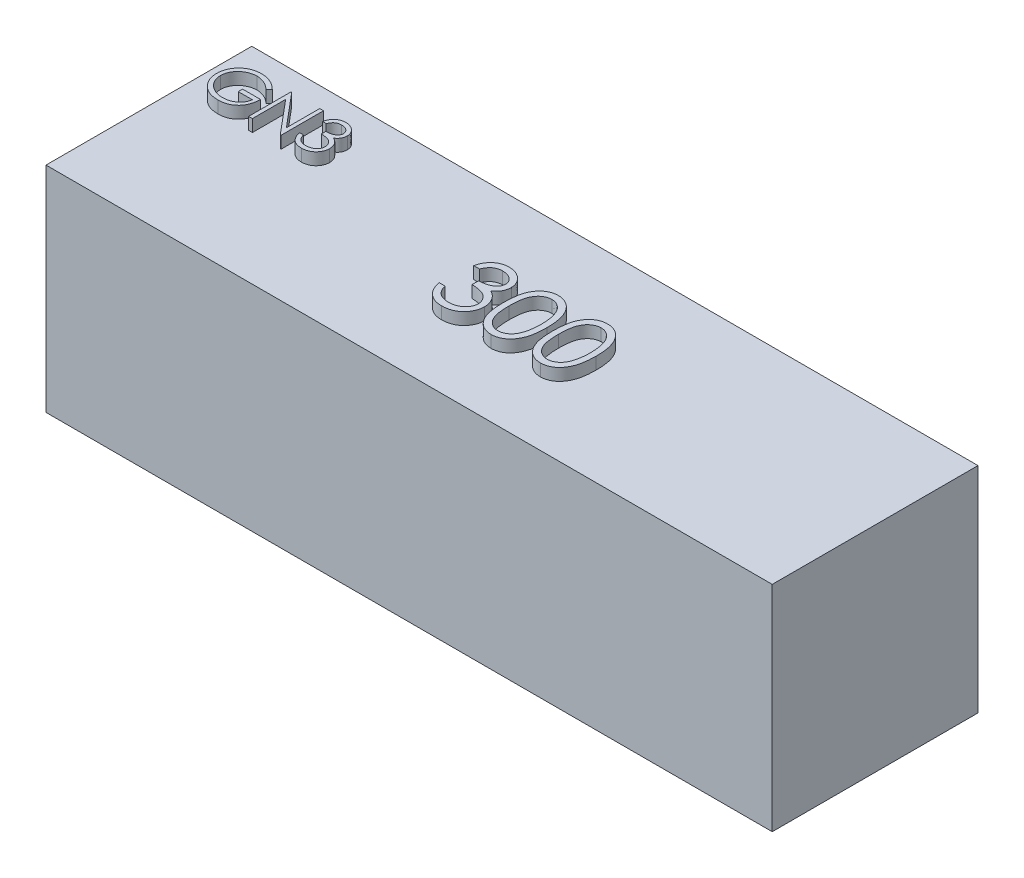
from build123d import *

# Parameters (mm, degrees)
SKETCH5_W           = 60
SKETCH5_H           = 17.7
BOSS_EXTRUDE2_DEPTH = 17
BOSS_EXTRUDE3_DEPTH = 1


with BuildPart() as part:
    # Sketch5 → Boss-Extrude2 (new body)
    with BuildSketch(Plane.XY):
        with Locations((30, 8.85)):
            Rectangle(SKETCH5_W, SKETCH5_H)
    extrude(amount=BOSS_EXTRUDE2_DEPTH)

    # Sketch6 → Boss-Extrude3 (add)
    with BuildSketch(Plane(origin=(0, 17.7, 0), x_dir=(1, 0, 0), z_dir=(0, 1, 0))):
        with BuildLine():
            Line((4.942496515, -3.246050022), (4.673265746, -3.501258356))
            add(Edge.make_bspline(
                [(4.673265746, -3.501258356), (4.624546858, -3.455427493), (4.528270811, -3.36485863), (4.371310569, -3.247347635), (4.207546935, -3.146681534), (4.037834438, -3.064775298), (3.866375884, -2.999422537), (3.695447107, -2.952894397), (3.526801406, -2.92322186), (3.414634188, -2.91967349), (3.359363502, -2.917925022)],
                knots=[0, 0, 0, 0, 0.000200536, 0.000396289, 0.000586999, 0.000776397, 0.000960787, 0.001136655, 0.001307246, 0.001472961, 0.001472961, 0.001472961, 0.001472961], degree=3))
            add(Edge.make_bspline(
                [(3.359363502, -2.917925022), (3.325448802, -2.918338628), (3.257707362, -2.919164767), (3.157085418, -2.929708983), (3.057518781, -2.944873847), (2.959195406, -2.966815724), (2.86192412, -2.994624784), (2.766043227, -3.029410247), (2.671373873, -3.069965491), (2.578807792, -3.116827965), (2.489067288, -3.168307811), (2.404310452, -3.225356352), (2.323997053, -3.286145142), (2.249636628, -3.352196121), (2.180801441, -3.422910987), (2.11585307, -3.496974293), (2.057075774, -3.576409511), (2.003984609, -3.659755137), (1.95662299, -3.745547327), (1.914814337, -3.832960316), (1.879717249, -3.921704171), (1.851947793, -4.011890248), (1.829037139, -4.102820838), (1.812919532, -4.195125559), (1.80383281, -4.288903244), (1.80226103, -4.351700503), (1.801470874, -4.383269574)],
                knots=[0, 0, 0, 0, 0.000101701, 0.000203139, 0.000303193, 0.000403728, 0.000505139, 0.000606491, 0.000709509, 0.000813922, 0.000917583, 0.001019673, 0.001120217, 0.001219549, 0.001317716, 0.001416124, 0.001514842, 0.00161384, 0.001712379, 0.001808658, 0.001904353, 0.001998376, 0.002091562, 0.002185504, 0.002279198, 0.002373914, 0.002373914, 0.002373914, 0.002373914], degree=3))
            add(Edge.make_bspline(
                [(1.801470874, -4.383269574), (1.802226592, -4.415540391), (1.803735965, -4.479993904), (1.813396285, -4.576187977), (1.831324525, -4.670953379), (1.855292234, -4.764601512), (1.88527305, -4.85729276), (1.922645716, -4.94862527), (1.966911316, -5.038595661), (2.018147868, -5.126393278), (2.074334072, -5.211916302), (2.137277153, -5.292475824), (2.204137736, -5.369144601), (2.277351636, -5.440220365), (2.354571178, -5.507604261), (2.438103454, -5.569439783), (2.526305915, -5.626918006), (2.619313127, -5.679314525), (2.716115909, -5.726123061), (2.815372662, -5.767746957), (2.917400478, -5.802026295), (3.021663168, -5.829964399), (3.128036439, -5.852864696), (3.237060242, -5.867597176), (3.34793295, -5.878288007), (3.422671582, -5.879069677), (3.460325041, -5.879463484)],
                knots=[0, 0, 0, 0, 9.6818e-05, 0.000193372, 0.000289633, 0.000385881, 0.000483216, 0.000581645, 0.00068167, 0.000783767, 0.00088644, 0.000988395, 0.001090231, 0.001191373, 0.001294266, 0.001397472, 0.001502873, 0.001609927, 0.001717482, 0.001825293, 0.001932604, 0.002040093, 0.002149, 0.002258763, 0.002369974, 0.002482889, 0.002482889, 0.002482889, 0.002482889], degree=3))
            add(Edge.make_bspline(
                [(3.460325041, -5.879463484), (3.505703388, -5.878514908), (3.594811145, -5.876652224), (3.725797588, -5.862151934), (3.851600659, -5.839505141), (3.971866862, -5.806339244), (4.086735883, -5.764035569), (4.196628824, -5.713040183), (4.300680483, -5.651397124), (4.399203656, -5.581823256), (4.489960842, -5.504308424), (4.571814966, -5.420663969), (4.643460455, -5.331295902), (4.705965154, -5.236730587), (4.757673809, -5.136185282), (4.800116604, -5.030152719), (4.832649895, -4.918585207), (4.84600487, -4.841493576), (4.852752925, -4.802540407)],
                knots=[0, 0, 0, 0, 0.000136106, 0.000267267, 0.000394882, 0.00051922, 0.000641, 0.000761758, 0.000882124, 0.001003321, 0.001123172, 0.001239687, 0.001353892, 0.00146629, 0.00157918, 0.001692449, 0.001808499, 0.001927028, 0.001927028, 0.001927028, 0.001927028], degree=3))
            Line((4.852752925, -4.802540407), (3.686086259, -4.802540407))
            Line((3.686086259, -4.802540407), (3.686086259, -4.443566048))
            Line((3.686086259, -4.443566048), (5.166855489, -4.443566048))
            add(Edge.make_bspline(
                [(5.166855489, -4.443566048), (5.165149641, -4.510473537), (5.161810988, -4.641423579), (5.138392072, -4.832393849), (5.10057556, -5.012765543), (5.048915248, -5.182728614), (4.982039968, -5.342042207), (4.900667439, -5.490868073), (4.803495318, -5.628244754), (4.693984877, -5.755293758), (4.571084919, -5.86862297), (4.438116299, -5.968228908), (4.29485933, -6.052131523), (4.141449523, -6.120392186), (3.978389089, -6.173666181), (3.80530071, -6.211437757), (3.622419109, -6.234067721), (3.497082432, -6.2369591), (3.432981291, -6.238437843)],
                knots=[0, 0, 0, 0, 0.000200697, 0.000392801, 0.000576238, 0.000752994, 0.000924878, 0.001093697, 0.001260784, 0.001428776, 0.001595974, 0.001761299, 0.001926279, 0.002092931, 0.002264096, 0.002439994, 0.002623661, 0.002815923, 0.002815923, 0.002815923, 0.002815923], degree=3))
            add(Edge.make_bspline(
                [(3.432981291, -6.238437843), (3.393471155, -6.237868722), (3.315544434, -6.236746231), (3.200453506, -6.228768884), (3.088535886, -6.216488307), (2.979807877, -6.197943184), (2.873869535, -6.17522853), (2.77124995, -6.146141811), (2.671558208, -6.112473112), (2.574640222, -6.074177438), (2.481375675, -6.029805781), (2.391349158, -5.980496142), (2.304063033, -5.926502781), (2.220111868, -5.866891936), (2.139058246, -5.802109475), (2.061424803, -5.732025556), (1.986776925, -5.656854437), (1.940016461, -5.603475427), (1.916454848, -5.576578868)],
                knots=[0, 0, 0, 0, 0.000118523, 0.000233765, 0.000345956, 0.000456148, 0.000564516, 0.000670839, 0.000775933, 0.000880089, 0.000983271, 0.001085557, 0.001187895, 0.001290998, 0.001394253, 0.001499002, 0.001604602, 0.001711853, 0.001711853, 0.001711853, 0.001711853], degree=3))
            add(Edge.make_bspline(
                [(1.916454848, -5.576578868), (1.882268916, -5.533908215), (1.814464504, -5.449275198), (1.727186347, -5.313675254), (1.652784944, -5.173273394), (1.592417122, -5.027678765), (1.545279036, -4.877027553), (1.511472783, -4.721512261), (1.491665494, -4.560932631), (1.488811957, -4.452267366), (1.48736831, -4.39729201)],
                knots=[0, 0, 0, 0, 0.00016394, 0.000325158, 0.000482912, 0.000640071, 0.000797293, 0.000955853, 0.00111691, 0.001281823, 0.001281823, 0.001281823, 0.001281823], degree=3))
            add(Edge.make_bspline(
                [(1.48736831, -4.39729201), (1.487900548, -4.356125757), (1.48895826, -4.274316449), (1.501783776, -4.152859142), (1.520185194, -4.03355845), (1.547232249, -3.916511893), (1.581328513, -3.801641302), (1.623881999, -3.688893338), (1.673426895, -3.578201466), (1.731012392, -3.470327598), (1.795096851, -3.366703185), (1.864647071, -3.267745382), (1.940650672, -3.175256317), (2.021866471, -3.088064669), (2.109263461, -3.007265822), (2.202022885, -2.932111711), (2.300216228, -2.862501525), (2.404152408, -2.799531691), (2.512280092, -2.74296807), (2.624340094, -2.693378858), (2.740298205, -2.652395543), (2.859285682, -2.617621763), (2.982203183, -2.591906623), (3.10815872, -2.573257877), (3.237808832, -2.560497278), (3.325444861, -2.559471022), (3.369880329, -2.558950663)],
                knots=[0, 0, 0, 0, 0.000123447, 0.000245326, 0.00036601, 0.000485407, 0.000605413, 0.000725221, 0.000846669, 0.000968994, 0.001091771, 0.00121199, 0.001331568, 0.001450618, 0.001569191, 0.001688326, 0.001808545, 0.001929991, 0.002052609, 0.002174413, 0.002297271, 0.002421315, 0.002546037, 0.002673651, 0.002803207, 0.002936466, 0.002936466, 0.002936466, 0.002936466], degree=3))
            add(Edge.make_bspline(
                [(3.369880329, -2.558950663), (3.406118573, -2.559530155), (3.477974752, -2.560679219), (3.584900484, -2.568643867), (3.690173499, -2.581267748), (3.793949888, -2.598494535), (3.895876255, -2.621958225), (3.99624296, -2.65003651), (4.095195496, -2.682728333), (4.192423745, -2.721717179), (4.288581461, -2.765970804), (4.384203302, -2.815784226), (4.478962548, -2.872009231), (4.573023529, -2.934812766), (4.666979387, -3.003116184), (4.75934403, -3.078873008), (4.852346974, -3.159095764), (4.912148788, -3.216777948), (4.942496515, -3.246050022)],
                knots=[0, 0, 0, 0, 0.00010871, 0.000215559, 0.000321482, 0.000426718, 0.00053098, 0.000635089, 0.000739295, 0.000843451, 0.000949174, 0.001056739, 0.001166761, 0.001279546, 0.001395941, 0.001515076, 0.00163782, 0.001764288, 0.001764288, 0.001764288, 0.001764288], degree=3))
        make_face()
        Polygon((5.884804207, -6.148694253), (5.884804207, -2.648694253), (5.950709656, -2.648694253), (8.263009336, -5.403401785), (8.263009336, -2.648694253), (8.5771119, -2.648694253), (8.5771119, -6.148694253), (8.505597477, -6.148694253), (6.198906771, -3.400296817), (6.198906771, -6.148694253), align=None)
        with BuildLine():
            Line((9.609163182, -3.456386561), (9.295060618, -3.456386561))
            add(Edge.make_bspline(
                [(9.295060618, -3.456386561), (9.303570168, -3.421154077), (9.320205644, -3.352277452), (9.354903217, -3.253870192), (9.392702473, -3.16074667), (9.438091577, -3.074650596), (9.487600331, -2.993851694), (9.544323053, -2.920182569), (9.605642775, -2.851769604), (9.673467725, -2.791056366), (9.744596386, -2.736078637), (9.820031006, -2.68920358), (9.8982539, -2.648879427), (9.979807033, -2.615659195), (10.064933204, -2.590633671), (10.152862828, -2.572476866), (10.243826328, -2.560685752), (10.305573918, -2.559534988), (10.336927605, -2.558950663)],
                knots=[0, 0, 0, 0, 0.000108665, 0.000212431, 0.000312691, 0.000409905, 0.000504067, 0.000596618, 0.000688443, 0.000779278, 0.000869306, 0.00095782, 0.001045306, 0.001133058, 0.001221569, 0.001311085, 0.001402223, 0.001496238, 0.001496238, 0.001496238, 0.001496238], degree=3))
            add(Edge.make_bspline(
                [(10.336927605, -2.558950663), (10.382610347, -2.560329894), (10.472979358, -2.563058269), (10.605742405, -2.587972706), (10.733769224, -2.627397838), (10.855658472, -2.681871565), (10.968876904, -2.749058878), (11.069613091, -2.829023615), (11.156501602, -2.920222917), (11.22939598, -3.020955481), (11.286470979, -3.12861099), (11.328557352, -3.239411147), (11.354179033, -3.353093119), (11.35749959, -3.429850398), (11.359163182, -3.468305631)],
                knots=[0, 0, 0, 0, 0.000136936, 0.000270885, 0.000403723, 0.000538055, 0.000670441, 0.000797677, 0.000922646, 0.001047185, 0.00116951, 0.001287103, 0.001401935, 0.001517226, 0.001517226, 0.001517226, 0.001517226], degree=3))
            add(Edge.make_bspline(
                [(11.359163182, -3.468305631), (11.357999591, -3.505312426), (11.355722624, -3.57772898), (11.336388918, -3.683450478), (11.303852655, -3.783092078), (11.258782893, -3.87707324), (11.200441342, -3.96479808), (11.129768645, -4.046463971), (11.046265984, -4.122433129), (10.982987046, -4.165952602), (10.950409175, -4.188357715)],
                knots=[0, 0, 0, 0, 0.000110957, 0.000217125, 0.000321111, 0.000424595, 0.000528824, 0.000636204, 0.000747885, 0.000866393, 0.000866393, 0.000866393, 0.000866393], degree=3))
            add(Edge.make_bspline(
                [(10.950409175, -4.188357715), (10.98764093, -4.206335886), (11.061407804, -4.241955844), (11.161958334, -4.311811601), (11.253236209, -4.392467949), (11.304139928, -4.455410602), (11.329716066, -4.487035599)],
                knots=[0, 0, 0, 0, 0.000123863, 0.000245408, 0.000366052, 0.000487879, 0.000487879, 0.000487879, 0.000487879], degree=3))
            add(Edge.make_bspline(
                [(11.329716066, -4.487035599), (11.346557409, -4.510093351), (11.379964305, -4.555831267), (11.421199839, -4.629367693), (11.458608953, -4.703719183), (11.487759172, -4.780878589), (11.510333039, -4.859951602), (11.526469071, -4.941073998), (11.536493212, -5.024312021), (11.537928764, -5.080624501), (11.538650361, -5.108930631)],
                knots=[0, 0, 0, 0, 8.5583e-05, 0.000169764, 0.000252544, 0.000335098, 0.000416766, 0.000498992, 0.000583001, 0.000667909, 0.000667909, 0.000667909, 0.000667909], degree=3))
            add(Edge.make_bspline(
                [(11.538650361, -5.108930631), (11.536855848, -5.157940352), (11.533275266, -5.255729154), (11.501271191, -5.400203876), (11.451657951, -5.541429378), (11.381201015, -5.676504217), (11.295333506, -5.802884598), (11.193176182, -5.915960908), (11.075889773, -6.013159512), (10.945084124, -6.09436974), (10.803366996, -6.159287662), (10.651791404, -6.204345105), (10.49254135, -6.233691105), (10.383334052, -6.236837974), (10.327813021, -6.238437843)],
                knots=[0, 0, 0, 0, 0.000146863, 0.000293035, 0.000441833, 0.000594857, 0.000748684, 0.000899086, 0.001050437, 0.001204129, 0.001359752, 0.001516561, 0.001677477, 0.001843893, 0.001843893, 0.001843893, 0.001843893], degree=3))
            add(Edge.make_bspline(
                [(10.327813021, -6.238437843), (10.290393721, -6.23756963), (10.216765016, -6.235861275), (10.108521518, -6.224182674), (10.005199818, -6.202852669), (9.906660221, -6.174149364), (9.812815184, -6.137757622), (9.723951079, -6.092438924), (9.639521185, -6.039127421), (9.560322234, -5.977193834), (9.486363667, -5.907912494), (9.419610942, -5.830053484), (9.358951149, -5.74505608), (9.306008511, -5.651933024), (9.258371558, -5.551887767), (9.219190601, -5.443639268), (9.184705033, -5.328155246), (9.168671569, -5.247677506), (9.160445233, -5.206386561)],
                knots=[0, 0, 0, 0, 0.000112258, 0.000220887, 0.000326076, 0.000428356, 0.000528479, 0.000627563, 0.000727152, 0.000827569, 0.00092875, 0.001030654, 0.001134734, 0.001241526, 0.001351611, 0.001466743, 0.00158655, 0.001712791, 0.001712791, 0.001712791, 0.001712791], degree=3))
            Line((9.160445233, -5.206386561), (9.474547797, -5.206386561))
            add(Edge.make_bspline(
                [(9.474547797, -5.206386561), (9.482731089, -5.233335574), (9.498648301, -5.285753746), (9.525742599, -5.361194051), (9.556610871, -5.430352105), (9.58972543, -5.493735227), (9.624503876, -5.551967629), (9.663418801, -5.603509498), (9.703587946, -5.6506247), (9.7338673, -5.677169312), (9.748686419, -5.690160599)],
                knots=[0, 0, 0, 0, 8.4487e-05, 0.000164335, 0.000240293, 0.00031148, 0.000378817, 0.000443461, 0.000505064, 0.000564113, 0.000564113, 0.000564113, 0.000564113], degree=3))
            add(Edge.make_bspline(
                [(9.748686419, -5.690160599), (9.768282995, -5.705268933), (9.807415658, -5.735438965), (9.871183889, -5.773940593), (9.938248776, -5.807301619), (10.01006345, -5.832785315), (10.08507822, -5.854362975), (10.164505585, -5.868483494), (10.247644803, -5.878171666), (10.304412566, -5.879026597), (10.333421996, -5.879463484)],
                knots=[0, 0, 0, 0, 7.418e-05, 0.000148131, 0.000223072, 0.000298488, 0.0003764, 0.000456984, 0.000540217, 0.000627201, 0.000627201, 0.000627201, 0.000627201], degree=3))
            add(Edge.make_bspline(
                [(10.333421996, -5.879463484), (10.366175498, -5.878847579), (10.430222145, -5.877643229), (10.523677005, -5.866567522), (10.612584452, -5.850437109), (10.695957378, -5.825524126), (10.774887885, -5.794743275), (10.848269535, -5.756094869), (10.917065641, -5.710750147), (10.980395047, -5.659210989), (11.037340554, -5.602789494), (11.087480067, -5.543776423), (11.130104729, -5.482420593), (11.164488307, -5.418382472), (11.191638857, -5.351927243), (11.210122058, -5.282868414), (11.222973573, -5.211771148), (11.224020185, -5.163442179), (11.224547797, -5.139078868)],
                knots=[0, 0, 0, 0, 9.822e-05, 0.00019206, 0.00028199, 0.000368957, 0.000452673, 0.000535779, 0.000617257, 0.000699492, 0.000780303, 0.000857417, 0.000931514, 0.001003978, 0.001075065, 0.001146335, 0.001218144, 0.001291145, 0.001291145, 0.001291145, 0.001291145], degree=3))
            add(Edge.make_bspline(
                [(11.224547797, -5.139078868), (11.223017496, -5.10646753), (11.219964507, -5.041407121), (11.196655928, -4.945689547), (11.158317063, -4.853466135), (11.104644552, -4.766310345), (11.039308824, -4.685534443), (10.962943917, -4.613462961), (10.874915688, -4.553992869), (10.793895819, -4.512904213), (10.722130663, -4.484867138), (10.660715278, -4.466192173), (10.591958675, -4.450378518), (10.516692326, -4.435666246), (10.43434911, -4.423144898), (10.345018672, -4.412703082), (10.24868291, -4.404348041), (10.181991744, -4.400616946), (10.14762472, -4.398694253)],
                knots=[0, 0, 0, 0, 9.7761e-05, 0.000195035, 0.000293731, 0.000396299, 0.00050098, 0.000604654, 0.000710058, 0.000818548, 0.000876487, 0.000941025, 0.001010919, 0.001088059, 0.001171055, 0.001260716, 0.001357836, 0.001461094, 0.001461094, 0.001461094, 0.001461094], degree=3))
            Line((10.14762472, -4.398694253), (10.14762472, -4.039719894))
            add(Edge.make_bspline(
                [(10.14762472, -4.039719894), (10.190925886, -4.03898509), (10.275742232, -4.03754579), (10.399636537, -4.02013778), (10.518109849, -3.996057152), (10.628536591, -3.95917196), (10.729185305, -3.916331663), (10.816504907, -3.866479453), (10.889272054, -3.811064704), (10.947133126, -3.749232095), (10.990662354, -3.682917047), (11.022489152, -3.61380039), (11.041289478, -3.541276329), (11.043799145, -3.491781661), (11.045060618, -3.466903388)],
                knots=[0, 0, 0, 0, 0.0001298, 0.000254247, 0.000374709, 0.000491998, 0.000602842, 0.000702416, 0.000792872, 0.000876214, 0.000955164, 0.001029842, 0.001103644, 0.00117823, 0.00117823, 0.00117823, 0.00117823], degree=3))
            add(Edge.make_bspline(
                [(11.045060618, -3.466903388), (11.044646207, -3.448625643), (11.043821756, -3.412262935), (11.033424478, -3.359137867), (11.017800437, -3.307636921), (10.996320708, -3.257979111), (10.967570509, -3.210508837), (10.933164522, -3.164821388), (10.892196422, -3.121177609), (10.845250975, -3.080497289), (10.79483917, -3.041728052), (10.739589395, -3.008814415), (10.68116752, -2.980669353), (10.619508866, -2.957459851), (10.554413335, -2.940000563), (10.486186778, -2.927464721), (10.414699094, -2.919627067), (10.365927362, -2.918498651), (10.341134336, -2.917925022)],
                knots=[0, 0, 0, 0, 5.4759e-05, 0.000108941, 0.000161726, 0.000216044, 0.000270754, 0.000327825, 0.00038735, 0.000449943, 0.000514025, 0.000577874, 0.000642472, 0.000708366, 0.000775209, 0.000844379, 0.000916308, 0.00099068, 0.00099068, 0.00099068, 0.00099068], degree=3))
            add(Edge.make_bspline(
                [(10.341134336, -2.917925022), (10.301282668, -2.919316384), (10.223443091, -2.922034038), (10.111228174, -2.945837051), (10.00690884, -2.983815135), (9.927170174, -3.029148154), (9.8682876, -3.073898588), (9.826210661, -3.112980975), (9.784890151, -3.156413798), (9.747044474, -3.206872173), (9.708770497, -3.260938964), (9.673925936, -3.321362645), (9.640066244, -3.386567039), (9.619663694, -3.432662674), (9.609163182, -3.456386561)],
                knots=[0, 0, 0, 0, 0.00011944, 0.000233294, 0.000342435, 0.0004514, 0.000506931, 0.000563998, 0.000623523, 0.000686492, 0.000753006, 0.000822147, 0.000895524, 0.000973336, 0.000973336, 0.000973336, 0.000973336], degree=3))
        make_face()
        with BuildLine():
            Line((26.337826552, -7.526092537), (25.86293339, -7.526092537))
            add(Edge.make_bspline(
                [(25.86293339, -7.526092537), (25.87579902, -7.472824376), (25.900950275, -7.36868948), (25.953409701, -7.219907074), (26.010558575, -7.079113178), (26.079182579, -6.948944114), (26.1540351, -6.826783868), (26.239794453, -6.715403168), (26.332504033, -6.61196928), (26.435048897, -6.520176647), (26.542588659, -6.437055557), (26.65663862, -6.366184934), (26.774904186, -6.305218655), (26.898204756, -6.254992829), (27.02690742, -6.21715662), (27.159848636, -6.189705259), (27.297376785, -6.171878218), (27.390733262, -6.170138374), (27.438137049, -6.16925493)],
                knots=[0, 0, 0, 0, 0.000164291, 0.000321175, 0.000472759, 0.000619737, 0.000762101, 0.000902029, 0.00104086, 0.001178194, 0.001314308, 0.001448132, 0.001580403, 0.001713076, 0.001846896, 0.001982236, 0.002120027, 0.00226217, 0.00226217, 0.00226217, 0.00226217], degree=3))
            add(Edge.make_bspline(
                [(27.438137049, -6.16925493), (27.507205004, -6.171340194), (27.643834342, -6.175465238), (27.844559425, -6.213133493), (28.038123783, -6.272740539), (28.222408717, -6.355099626), (28.393584204, -6.456680445), (28.545887725, -6.577579511), (28.677254878, -6.71546417), (28.787464235, -6.867762213), (28.873756198, -7.030527091), (28.937386786, -7.198046376), (28.976124328, -7.36992269), (28.981144693, -7.485972386), (28.983659886, -7.544113036)],
                knots=[0, 0, 0, 0, 0.000207034, 0.000409553, 0.000610391, 0.000813488, 0.001013643, 0.001206012, 0.001394953, 0.001583244, 0.001768188, 0.001945977, 0.002119592, 0.002293901, 0.002293901, 0.002293901, 0.002293901], degree=3))
            add(Edge.make_bspline(
                [(28.983659886, -7.544113036), (28.981900647, -7.600063785), (28.978458089, -7.709550719), (28.949227368, -7.869391554), (28.900035637, -8.020040164), (28.831894449, -8.16213073), (28.743687581, -8.294762333), (28.636837194, -8.418233382), (28.510589122, -8.533091514), (28.414917394, -8.598888813), (28.365662757, -8.63276321)],
                knots=[0, 0, 0, 0, 0.000167756, 0.000328273, 0.00048549, 0.000641947, 0.000799532, 0.000961879, 0.00113073, 0.001309904, 0.001309904, 0.001309904, 0.001309904], degree=3))
            add(Edge.make_bspline(
                [(28.365662757, -8.63276321), (28.421953624, -8.659944493), (28.533482113, -8.713798476), (28.685504937, -8.819413729), (28.823508391, -8.941358444), (28.900469966, -9.036521741), (28.939138652, -9.084335726)],
                knots=[0, 0, 0, 0, 0.000187269, 0.000371033, 0.000553435, 0.000737627, 0.000737627, 0.000737627, 0.000737627], degree=3))
            add(Edge.make_bspline(
                [(28.939138652, -9.084335726), (28.964601157, -9.11919685), (29.015109203, -9.188348224), (29.077453403, -9.299528296), (29.134012421, -9.411940667), (29.178084776, -9.52859834), (29.212214313, -9.648149206), (29.236610457, -9.770798543), (29.251766003, -9.896646506), (29.253936421, -9.981785613), (29.255027407, -10.024581786)],
                knots=[0, 0, 0, 0, 0.000129393, 0.000256667, 0.000381823, 0.000506636, 0.00063011, 0.000754428, 0.000881441, 0.001009814, 0.001009814, 0.001009814, 0.001009814], degree=3))
            add(Edge.make_bspline(
                [(29.255027407, -10.024581786), (29.252314274, -10.098679817), (29.246900775, -10.246527172), (29.198513662, -10.464959192), (29.123503167, -10.678478701), (29.01697899, -10.882698994), (28.887155495, -11.073774093), (28.73270335, -11.244734704), (28.555377471, -11.391689736), (28.357611787, -11.514471867), (28.143348986, -11.612621583), (27.914181126, -11.680744145), (27.673410212, -11.725112502), (27.508299178, -11.729870268), (27.424356667, -11.732289118)],
                knots=[0, 0, 0, 0, 0.000222043, 0.00044304, 0.000668009, 0.000899367, 0.001131939, 0.001359332, 0.001588161, 0.001820528, 0.002055816, 0.002292896, 0.002536186, 0.00278779, 0.00278779, 0.00278779, 0.00278779], degree=3))
            add(Edge.make_bspline(
                [(27.424356667, -11.732289118), (27.367782249, -11.730976462), (27.256462659, -11.728393593), (27.092808799, -11.71073666), (26.936596229, -11.678487724), (26.787613742, -11.63509106), (26.645728985, -11.580070212), (26.511374921, -11.511552656), (26.383724963, -11.430950743), (26.263983691, -11.337313056), (26.152165381, -11.232566269), (26.051241619, -11.114850861), (25.959529789, -10.986342881), (25.879485562, -10.845549689), (25.807463026, -10.694290788), (25.748225151, -10.530629368), (25.696086256, -10.356028525), (25.671845185, -10.234353846), (25.659407749, -10.17192587)],
                knots=[0, 0, 0, 0, 0.000169724, 0.00033396, 0.000492996, 0.000647633, 0.00079901, 0.000948816, 0.001099385, 0.001251206, 0.001404181, 0.00155825, 0.00171561, 0.001877069, 0.002043507, 0.002217575, 0.002398713, 0.002589577, 0.002589577, 0.002589577, 0.002589577], degree=3))
            Line((25.659407749, -10.17192587), (26.134300911, -10.17192587))
            add(Edge.make_bspline(
                [(26.134300911, -10.17192587), (26.146673269, -10.212670211), (26.170738578, -10.291921495), (26.211702577, -10.405980052), (26.258372464, -10.510540442), (26.308438523, -10.606369686), (26.361020221, -10.694411533), (26.419855882, -10.77233793), (26.480587804, -10.843571628), (26.526367302, -10.883704554), (26.548772399, -10.903346142)],
                knots=[0, 0, 0, 0, 0.000127737, 0.000248459, 0.0003633, 0.000470928, 0.000572735, 0.000670471, 0.000763609, 0.000852884, 0.000852884, 0.000852884, 0.000852884], degree=3))
            add(Edge.make_bspline(
                [(26.548772399, -10.903346142), (26.578400556, -10.926188504), (26.637565416, -10.971802719), (26.733976908, -11.030013514), (26.835372629, -11.080452208), (26.943949577, -11.118981128), (27.057364765, -11.151604497), (27.177451377, -11.172953377), (27.303149955, -11.187600969), (27.388977407, -11.188893544), (27.432836902, -11.189554075)],
                knots=[0, 0, 0, 0, 0.000112153, 0.00022396, 0.000337264, 0.000451285, 0.000569082, 0.000690916, 0.000816756, 0.000948268, 0.000948268, 0.000948268, 0.000948268], degree=3))
            add(Edge.make_bspline(
                [(27.432836902, -11.189554075), (27.482357079, -11.188622885), (27.579189509, -11.186802023), (27.720484356, -11.170056609), (27.85490395, -11.14566896), (27.980955873, -11.108002903), (28.100291283, -11.061465187), (28.211237348, -11.003032479), (28.315250509, -10.934475578), (28.410998539, -10.856553279), (28.497094723, -10.771249352), (28.572900891, -10.682027209), (28.63734532, -10.589263038), (28.689330016, -10.492443498), (28.730379062, -10.391969521), (28.758323901, -10.287559148), (28.777754168, -10.180066852), (28.779336546, -10.106998054), (28.780134245, -10.070163049)],
                knots=[0, 0, 0, 0, 0.000148499, 0.000290376, 0.000426341, 0.000557828, 0.000684398, 0.000810046, 0.000933233, 0.001057565, 0.001179744, 0.001296333, 0.001408361, 0.001517919, 0.001625395, 0.001733149, 0.001841718, 0.001952088, 0.001952088, 0.001952088, 0.001952088], degree=3))
            add(Edge.make_bspline(
                [(28.780134245, -10.070163049), (28.777820575, -10.020857811), (28.773204747, -9.92249267), (28.737964394, -9.777776813), (28.679999683, -9.638343797), (28.598851958, -9.506572543), (28.500070558, -9.384447073), (28.384614092, -9.275481855), (28.251523794, -9.185568741), (28.129029469, -9.123446606), (28.020527387, -9.081057219), (27.927673175, -9.052822451), (27.823719739, -9.02891371), (27.709924187, -9.006670156), (27.585429086, -8.98773907), (27.450369972, -8.971952039), (27.304719475, -8.959320013), (27.203888784, -8.953678952), (27.151929117, -8.950772024)],
                knots=[0, 0, 0, 0, 0.000147805, 0.000294874, 0.000444094, 0.000599166, 0.000757434, 0.000914179, 0.001073539, 0.001237567, 0.001325165, 0.00142274, 0.001528414, 0.001645041, 0.001770524, 0.001906083, 0.002052919, 0.002209035, 0.002209035, 0.002209035, 0.002209035], degree=3))
            Line((27.151929117, -8.950772024), (27.151929117, -8.408036981))
            add(Edge.make_bspline(
                [(27.151929117, -8.408036981), (27.217396355, -8.406926028), (27.345630593, -8.404749943), (27.532946983, -8.378430689), (27.712067348, -8.342023073), (27.879022065, -8.286256175), (28.031193334, -8.221485727), (28.163212256, -8.146113934), (28.273229252, -8.06233211), (28.360709682, -7.968847094), (28.42652173, -7.868585058), (28.474640816, -7.764087254), (28.503065119, -7.654437781), (28.506859497, -7.579606557), (28.508766723, -7.541992977)],
                knots=[0, 0, 0, 0, 0.000196246, 0.000384397, 0.000566525, 0.000743854, 0.00091144, 0.001061986, 0.001198746, 0.001324752, 0.001444117, 0.001557024, 0.001668604, 0.001781371, 0.001781371, 0.001781371, 0.001781371], degree=3))
            add(Edge.make_bspline(
                [(28.508766723, -7.541992977), (28.508140173, -7.514358767), (28.506893682, -7.459381817), (28.491173988, -7.379061773), (28.467551926, -7.301197248), (28.435076621, -7.226119368), (28.391609059, -7.154348835), (28.339590484, -7.085273763), (28.277650618, -7.019288526), (28.206673573, -6.957783757), (28.130455725, -6.899168363), (28.046923327, -6.849406078), (27.958595017, -6.806853425), (27.865373003, -6.771762868), (27.766954761, -6.745366087), (27.663802703, -6.726413089), (27.555720134, -6.714563301), (27.48198192, -6.712857244), (27.444497225, -6.711989972)],
                knots=[0, 0, 0, 0, 8.2791e-05, 0.000164709, 0.000244514, 0.000326637, 0.000409354, 0.00049564, 0.000585637, 0.000680271, 0.000777158, 0.00087369, 0.000971357, 0.001070983, 0.001172042, 0.00127662, 0.00138537, 0.001497813, 0.001497813, 0.001497813, 0.001497813], degree=3))
            add(Edge.make_bspline(
                [(27.444497225, -6.711989972), (27.384245299, -6.714093579), (27.266559273, -6.718202413), (27.096901005, -6.754190302), (26.939180108, -6.811609547), (26.818622838, -6.880148755), (26.729597994, -6.947807149), (26.66598167, -7.006895995), (26.603508994, -7.072562288), (26.546289935, -7.148850546), (26.488423327, -7.230594384), (26.435741669, -7.321949236), (26.384549039, -7.42053207), (26.353702327, -7.490224279), (26.337826552, -7.526092537)],
                knots=[0, 0, 0, 0, 0.000180582, 0.000352718, 0.000517729, 0.000682474, 0.000766431, 0.000852711, 0.000942708, 0.00103791, 0.001138473, 0.001243008, 0.001353947, 0.001471591, 0.001471591, 0.001471591, 0.001471591], degree=3))
        make_face()
        with BuildLine():
            add(Edge.make_bspline(
                [(29.72992057, -8.952892082), (29.730416502, -8.868078175), (29.731379857, -8.703325937), (29.742096875, -8.46325868), (29.759900071, -8.23804491), (29.784298242, -8.027673846), (29.813988997, -7.832091178), (29.853624316, -7.651819581), (29.898698435, -7.4860247), (29.950938442, -7.334165888), (30.009884266, -7.194197218), (30.074040827, -7.063530545), (30.145954266, -6.942363576), (30.221514599, -6.828762392), (30.303780469, -6.724586568), (30.390410783, -6.628364924), (30.484786715, -6.542321289), (30.583700073, -6.463934618), (30.688046394, -6.395219345), (30.794851377, -6.334693657), (30.904850168, -6.282986715), (31.018343087, -6.242330937), (31.13431005, -6.208750252), (31.253156448, -6.185786009), (31.375078511, -6.171336874), (31.457373656, -6.169955495), (31.499109605, -6.16925493)],
                knots=[0, 0, 0, 0, 0.000254427, 0.000494228, 0.000720732, 0.000932029, 0.001129482, 0.001313906, 0.001485438, 0.001644672, 0.001795278, 0.001940815, 0.002080984, 0.002217695, 0.002349808, 0.00247887, 0.002605653, 0.002732468, 0.002857124, 0.00298006, 0.003100517, 0.003221239, 0.003341364, 0.003462356, 0.003583983, 0.003709138, 0.003709138, 0.003709138, 0.003709138], degree=3))
            add(Edge.make_bspline(
                [(31.499109605, -6.16925493), (31.541194198, -6.16999246), (31.624887211, -6.171459175), (31.748622064, -6.185556088), (31.869498369, -6.208946953), (31.987000793, -6.242089379), (32.102094522, -6.283206652), (32.213879329, -6.334743126), (32.32304956, -6.394733795), (32.427870352, -6.465224657), (32.529492449, -6.543816908), (32.625419726, -6.632660467), (32.715660915, -6.730858257), (32.801348579, -6.837359646), (32.880051685, -6.954207334), (32.955001993, -7.079369024), (33.022088285, -7.215033545), (33.086699044, -7.358937348), (33.142468655, -7.515062165), (33.19276405, -7.682527934), (33.23340249, -7.863312717), (33.267252938, -8.056467992), (33.293476769, -8.262703116), (33.31257612, -8.481575998), (33.322665189, -8.713230636), (33.324565202, -8.871614527), (33.325540228, -8.952892082)],
                knots=[0, 0, 0, 0, 0.000126215, 0.000251001, 0.000373034, 0.0004952, 0.000616918, 0.0007393, 0.000864087, 0.000990213, 0.001117861, 0.001249138, 0.001381913, 0.001517663, 0.00165879, 0.001804227, 0.001954979, 0.002112549, 0.002277195, 0.002451933, 0.002636819, 0.002832704, 0.00304005, 0.003260304, 0.003491634, 0.003735477, 0.003735477, 0.003735477, 0.003735477], degree=3))
            add(Edge.make_bspline(
                [(33.325540228, -8.952892082), (33.324555094, -9.033815134), (33.322635601, -9.191490399), (33.312689223, -9.422102707), (33.293097007, -9.639814034), (33.268589048, -9.845146519), (33.23464533, -10.037245538), (33.192908948, -10.216775835), (33.146568579, -10.384512706), (33.089365974, -10.539082004), (33.026756923, -10.682639966), (32.958637758, -10.81669625), (32.885658378, -10.942435764), (32.806149204, -11.058852048), (32.721401781, -11.166769779), (32.629602267, -11.264284042), (32.533338407, -11.353744463), (32.431417254, -11.433348709), (32.324961695, -11.503024545), (32.216166423, -11.565335961), (32.10310107, -11.615580631), (31.988327915, -11.658722896), (31.870205267, -11.691683103), (31.748880366, -11.714473337), (31.624970343, -11.730456965), (31.541208453, -11.731676285), (31.499109605, -11.732289118)],
                knots=[0, 0, 0, 0, 0.000242784, 0.000473054, 0.000692252, 0.000898414, 0.001093255, 0.001277108, 0.001451253, 0.001614903, 0.001771077, 0.001920882, 0.002065781, 0.002206908, 0.002343488, 0.002476984, 0.002608261, 0.002737398, 0.002864407, 0.00298971, 0.003113057, 0.00323514, 0.003357305, 0.003480379, 0.003605287, 0.003731501, 0.003731501, 0.003731501, 0.003731501], degree=3))
            add(Edge.make_bspline(
                [(31.499109605, -11.732289118), (31.457374814, -11.731584033), (31.375081951, -11.730193743), (31.253143165, -11.715809887), (31.134787566, -11.692684543), (31.019431117, -11.660304677), (30.906481981, -11.620670341), (30.797479262, -11.569033224), (30.691210978, -11.509563858), (30.587960649, -11.441837447), (30.489668454, -11.36424395), (30.395781276, -11.278421751), (30.308657736, -11.182229213), (30.227568091, -11.07718521), (30.150500124, -10.964256141), (30.079607858, -10.841900149), (30.014035257, -10.710602392), (29.954098075, -10.569514599), (29.900956643, -10.416577982), (29.854015465, -10.250042914), (29.816952394, -10.068439512), (29.785228164, -9.87322635), (29.759640108, -9.663564574), (29.742171069, -9.439340362), (29.731374081, -9.200693439), (29.730413915, -9.036999852), (29.72992057, -8.952892082)],
                knots=[0, 0, 0, 0, 0.000125155, 0.000246782, 0.000367774, 0.000486592, 0.000605957, 0.000726414, 0.000847906, 0.000971093, 0.001096419, 0.001223202, 0.001352265, 0.001485213, 0.001621046, 0.001762129, 0.001909088, 0.002061083, 0.002221666, 0.002394503, 0.002579741, 0.002777362, 0.002987732, 0.003213179, 0.003451922, 0.003704229, 0.003704229, 0.003704229, 0.003704229], degree=3))
        make_face()
        with BuildLine():
            add(Edge.make_bspline(
                [(30.204813732, -8.950772024), (30.204994324, -9.021451604), (30.205344819, -9.158626791), (30.214501218, -9.357961245), (30.226974783, -9.543880671), (30.243063411, -9.716621136), (30.266955964, -9.875597941), (30.293726941, -10.021904486), (30.3263056, -10.154766499), (30.364851639, -10.275095689), (30.408755988, -10.384934162), (30.456692234, -10.487140761), (30.508188803, -10.582922855), (30.565821328, -10.671420096), (30.62858815, -10.752921082), (30.69507153, -10.828868341), (30.767752699, -10.89659711), (30.868300024, -10.977826998), (31.001039932, -11.061766641), (31.168287525, -11.134861324), (31.340143397, -11.180796705), (31.45678874, -11.186638336), (31.515010046, -11.189554075)],
                knots=[0, 0, 0, 0, 0.000212016, 0.000411482, 0.000598481, 0.000771041, 0.000931746, 0.001080604, 0.001217122, 0.001341827, 0.001459343, 0.001571731, 0.001680356, 0.001785321, 0.001888149, 0.001988768, 0.002087755, 0.00218576, 0.00237633, 0.002556722, 0.002731806, 0.002906283, 0.002906283, 0.002906283, 0.002906283], degree=3))
            add(Edge.make_bspline(
                [(31.515010046, -11.189554075), (31.573607954, -11.187138383), (31.690682788, -11.182311985), (31.861730312, -11.135747228), (32.02778322, -11.06548971), (32.157915797, -10.982414314), (32.256919166, -10.903298864), (32.327853187, -10.835845765), (32.392958903, -10.760317251), (32.45470823, -10.678826649), (32.511342785, -10.58981706), (32.562843005, -10.493716499), (32.609838066, -10.3902581), (32.636612457, -10.318034804), (32.650301512, -10.281108896)],
                knots=[0, 0, 0, 0, 0.000175447, 0.000350532, 0.000528136, 0.000714885, 0.0008114, 0.000908119, 0.001008037, 0.001110224, 0.001214614, 0.001324172, 0.001437079, 0.001555195, 0.001555195, 0.001555195, 0.001555195], degree=3))
            add(Edge.make_bspline(
                [(32.650301512, -10.281108896), (32.66625478, -10.233892504), (32.698646756, -10.13802298), (32.740393129, -9.989306506), (32.773270102, -9.833273755), (32.802848047, -9.67085721), (32.823036596, -9.500859091), (32.839286266, -9.323805391), (32.848857662, -9.139562617), (32.850044131, -9.014384476), (32.850647065, -8.950772024)],
                knots=[0, 0, 0, 0, 0.000149505, 0.00030356, 0.000463034, 0.000627724, 0.000798649, 0.000976387, 0.001161078, 0.00135191, 0.00135191, 0.00135191, 0.00135191], degree=3))
            add(Edge.make_bspline(
                [(32.850647065, -8.950772024), (32.849815232, -8.88716986), (32.848187987, -8.762750433), (32.841968029, -8.580538422), (32.825906196, -8.407474069), (32.808067052, -8.242811806), (32.781764111, -8.087463135), (32.753404094, -7.940127554), (32.715302261, -7.802630362), (32.674602125, -7.672818851), (32.628019741, -7.552167862), (32.576742381, -7.440114875), (32.521978531, -7.336118922), (32.462496811, -7.240465332), (32.399003337, -7.152725654), (32.329822281, -7.074659065), (32.257697812, -7.00384603), (32.156676591, -6.923015717), (32.024423796, -6.840599225), (31.859859543, -6.764753374), (31.688605117, -6.721197979), (31.572833347, -6.715057095), (31.515010046, -6.711989972)],
                knots=[0, 0, 0, 0, 0.000190832, 0.000373308, 0.000546729, 0.000712137, 0.000870025, 0.00101929, 0.001162001, 0.001297771, 0.001427303, 0.001549685, 0.001667286, 0.001779649, 0.001887356, 0.001991762, 0.002092213, 0.002190219, 0.002379326, 0.002558208, 0.002732004, 0.002905425, 0.002905425, 0.002905425, 0.002905425], degree=3))
            add(Edge.make_bspline(
                [(31.515010046, -6.711989972), (31.456483317, -6.715061326), (31.339323239, -6.721209629), (31.166288831, -6.764591096), (31.000426299, -6.840205937), (30.868523231, -6.923288691), (30.767431553, -7.002419233), (30.696247005, -7.071039229), (30.629502197, -7.146099638), (30.568016507, -7.228350152), (30.510429139, -7.316744219), (30.457541179, -7.411977232), (30.409889979, -7.514531795), (30.36591693, -7.624320929), (30.32725331, -7.744639738), (30.295361246, -7.877338098), (30.265898678, -8.023179291), (30.245041545, -8.183017119), (30.226499914, -8.355800851), (30.214584067, -8.542184415), (30.20531419, -8.741853181), (30.204983892, -8.879737623), (30.204813732, -8.950772024)],
                knots=[0, 0, 0, 0, 0.000175533, 0.000351386, 0.000531236, 0.000720343, 0.000817687, 0.000915904, 0.001016524, 0.001118711, 0.001223675, 0.001332812, 0.0014452, 0.001562715, 0.00168742, 0.001823938, 0.001971956, 0.00213356, 0.002307282, 0.002493223, 0.002693748, 0.002906825, 0.002906825, 0.002906825, 0.002906825], degree=3))
        make_face(mode=Mode.SUBTRACT)
        with BuildLine():
            add(Edge.make_bspline(
                [(33.80043339, -8.952892082), (33.800929322, -8.868078175), (33.801892678, -8.703325937), (33.812609695, -8.46325868), (33.830412891, -8.23804491), (33.854811062, -8.027673846), (33.884501818, -7.832091178), (33.924137137, -7.651819581), (33.969211255, -7.4860247), (34.021451262, -7.334165888), (34.080397086, -7.194197218), (34.144553647, -7.063530545), (34.216467086, -6.942363576), (34.292027419, -6.828762392), (34.374293289, -6.724586568), (34.460923603, -6.628364924), (34.555299535, -6.542321289), (34.654212893, -6.463934618), (34.758559214, -6.395219345), (34.865364198, -6.334693657), (34.975362989, -6.282986715), (35.088855908, -6.242330937), (35.204822871, -6.208750252), (35.323669269, -6.185786009), (35.445591331, -6.171336874), (35.527886477, -6.169955495), (35.569622426, -6.16925493)],
                knots=[0, 0, 0, 0, 0.000254427, 0.000494228, 0.000720732, 0.000932029, 0.001129482, 0.001313906, 0.001485438, 0.001644672, 0.001795278, 0.001940815, 0.002080984, 0.002217695, 0.002349808, 0.00247887, 0.002605653, 0.002732468, 0.002857124, 0.00298006, 0.003100517, 0.003221239, 0.003341364, 0.003462356, 0.003583983, 0.003709138, 0.003709138, 0.003709138, 0.003709138], degree=3))
            add(Edge.make_bspline(
                [(35.569622426, -6.16925493), (35.611707018, -6.16999246), (35.695400032, -6.171459175), (35.819134885, -6.185556088), (35.940011189, -6.208946953), (36.057513613, -6.242089379), (36.172607343, -6.283206652), (36.28439215, -6.334743126), (36.39356238, -6.394733795), (36.498383172, -6.465224657), (36.600005269, -6.543816908), (36.695932546, -6.632660467), (36.786173736, -6.730858257), (36.8718614, -6.837359646), (36.950564505, -6.954207334), (37.025514813, -7.079369024), (37.092601106, -7.215033545), (37.157211865, -7.358937348), (37.212981476, -7.515062165), (37.26327687, -7.682527934), (37.303915311, -7.863312717), (37.337765758, -8.056467992), (37.363989589, -8.262703116), (37.383088941, -8.481575998), (37.39317801, -8.713230636), (37.395078022, -8.871614527), (37.396053048, -8.952892082)],
                knots=[0, 0, 0, 0, 0.000126215, 0.000251001, 0.000373034, 0.0004952, 0.000616918, 0.0007393, 0.000864087, 0.000990213, 0.001117861, 0.001249138, 0.001381913, 0.001517663, 0.00165879, 0.001804227, 0.001954979, 0.002112549, 0.002277195, 0.002451933, 0.002636819, 0.002832704, 0.00304005, 0.003260304, 0.003491634, 0.003735477, 0.003735477, 0.003735477, 0.003735477], degree=3))
            add(Edge.make_bspline(
                [(37.396053048, -8.952892082), (37.395067914, -9.033815134), (37.393148421, -9.191490399), (37.383202043, -9.422102707), (37.363609827, -9.639814034), (37.339101869, -9.845146519), (37.305158151, -10.037245538), (37.263421768, -10.216775835), (37.217081399, -10.384512706), (37.159878794, -10.539082004), (37.097269744, -10.682639966), (37.029150578, -10.81669625), (36.956171198, -10.942435764), (36.876662024, -11.058852048), (36.791914602, -11.166769779), (36.700115088, -11.264284042), (36.603851227, -11.353744463), (36.501930075, -11.433348709), (36.395474515, -11.503024545), (36.286679244, -11.565335961), (36.173613891, -11.615580631), (36.058840736, -11.658722896), (35.940718087, -11.691683103), (35.819393187, -11.714473337), (35.695483164, -11.730456965), (35.611721273, -11.731676285), (35.569622426, -11.732289118)],
                knots=[0, 0, 0, 0, 0.000242784, 0.000473054, 0.000692252, 0.000898414, 0.001093255, 0.001277108, 0.001451253, 0.001614903, 0.001771077, 0.001920882, 0.002065781, 0.002206908, 0.002343488, 0.002476984, 0.002608261, 0.002737398, 0.002864407, 0.00298971, 0.003113057, 0.00323514, 0.003357305, 0.003480379, 0.003605287, 0.003731501, 0.003731501, 0.003731501, 0.003731501], degree=3))
            add(Edge.make_bspline(
                [(35.569622426, -11.732289118), (35.527887634, -11.731584033), (35.445594772, -11.730193743), (35.323655986, -11.715809887), (35.205300387, -11.692684543), (35.089943937, -11.660304677), (34.976994801, -11.620670341), (34.867992082, -11.569033224), (34.761723799, -11.509563858), (34.65847347, -11.441837447), (34.560181274, -11.36424395), (34.466294097, -11.278421751), (34.379170556, -11.182229213), (34.298080912, -11.07718521), (34.221012945, -10.964256141), (34.150120678, -10.841900149), (34.084548077, -10.710602392), (34.024610895, -10.569514599), (33.971469463, -10.416577982), (33.924528286, -10.250042914), (33.887465214, -10.068439512), (33.855740984, -9.87322635), (33.830152929, -9.663564574), (33.812683889, -9.439340362), (33.801886901, -9.200693439), (33.800926735, -9.036999852), (33.80043339, -8.952892082)],
                knots=[0, 0, 0, 0, 0.000125155, 0.000246782, 0.000367774, 0.000486592, 0.000605957, 0.000726414, 0.000847906, 0.000971093, 0.001096419, 0.001223202, 0.001352265, 0.001485213, 0.001621046, 0.001762129, 0.001909088, 0.002061083, 0.002221666, 0.002394503, 0.002579741, 0.002777362, 0.002987732, 0.003213179, 0.003451922, 0.003704229, 0.003704229, 0.003704229, 0.003704229], degree=3))
        make_face()
        with BuildLine():
            add(Edge.make_bspline(
                [(34.275326552, -8.950772024), (34.275507145, -9.021451604), (34.27585764, -9.158626791), (34.285014038, -9.357961245), (34.297487603, -9.543880671), (34.313576231, -9.716621136), (34.337468784, -9.875597941), (34.364239761, -10.021904486), (34.39681842, -10.154766499), (34.435364459, -10.275095689), (34.479268808, -10.384934162), (34.527205054, -10.487140761), (34.578701624, -10.582922855), (34.636334149, -10.671420096), (34.699100971, -10.752921082), (34.765584351, -10.828868341), (34.83826552, -10.89659711), (34.938812845, -10.977826998), (35.071552752, -11.061766641), (35.238800345, -11.134861324), (35.410656218, -11.180796705), (35.52730156, -11.186638336), (35.585522867, -11.189554075)],
                knots=[0, 0, 0, 0, 0.000212016, 0.000411482, 0.000598481, 0.000771041, 0.000931746, 0.001080604, 0.001217122, 0.001341827, 0.001459343, 0.001571731, 0.001680356, 0.001785321, 0.001888149, 0.001988768, 0.002087755, 0.00218576, 0.00237633, 0.002556722, 0.002731806, 0.002906283, 0.002906283, 0.002906283, 0.002906283], degree=3))
            add(Edge.make_bspline(
                [(35.585522867, -11.189554075), (35.644120775, -11.187138383), (35.761195609, -11.182311985), (35.932243132, -11.135747228), (36.098296041, -11.06548971), (36.228428617, -10.982414314), (36.327431986, -10.903298864), (36.398366007, -10.835845765), (36.463471723, -10.760317251), (36.525221051, -10.678826649), (36.581855606, -10.58981706), (36.633355826, -10.493716499), (36.680350887, -10.3902581), (36.707125278, -10.318034804), (36.720814333, -10.281108896)],
                knots=[0, 0, 0, 0, 0.000175447, 0.000350532, 0.000528136, 0.000714885, 0.0008114, 0.000908119, 0.001008037, 0.001110224, 0.001214614, 0.001324172, 0.001437079, 0.001555195, 0.001555195, 0.001555195, 0.001555195], degree=3))
            add(Edge.make_bspline(
                [(36.720814333, -10.281108896), (36.736767601, -10.233892504), (36.769159577, -10.13802298), (36.81090595, -9.989306506), (36.843782922, -9.833273755), (36.873360868, -9.67085721), (36.893549417, -9.500859091), (36.909799087, -9.323805391), (36.919370483, -9.139562617), (36.920556951, -9.014384476), (36.921159886, -8.950772024)],
                knots=[0, 0, 0, 0, 0.000149505, 0.00030356, 0.000463034, 0.000627724, 0.000798649, 0.000976387, 0.001161078, 0.00135191, 0.00135191, 0.00135191, 0.00135191], degree=3))
            add(Edge.make_bspline(
                [(36.921159886, -8.950772024), (36.920328052, -8.88716986), (36.918700807, -8.762750433), (36.91248085, -8.580538422), (36.896419017, -8.407474069), (36.878579873, -8.242811806), (36.852276932, -8.087463135), (36.823916914, -7.940127554), (36.785815081, -7.802630362), (36.745114945, -7.672818851), (36.698532561, -7.552167862), (36.647255201, -7.440114875), (36.592491352, -7.336118922), (36.533009631, -7.240465332), (36.469516158, -7.152725654), (36.400335101, -7.074659065), (36.328210633, -7.00384603), (36.227189412, -6.923015717), (36.094936616, -6.840599225), (35.930372364, -6.764753374), (35.759117937, -6.721197979), (35.643346167, -6.715057095), (35.585522867, -6.711989972)],
                knots=[0, 0, 0, 0, 0.000190832, 0.000373308, 0.000546729, 0.000712137, 0.000870025, 0.00101929, 0.001162001, 0.001297771, 0.001427303, 0.001549685, 0.001667286, 0.001779649, 0.001887356, 0.001991762, 0.002092213, 0.002190219, 0.002379326, 0.002558208, 0.002732004, 0.002905425, 0.002905425, 0.002905425, 0.002905425], degree=3))
            add(Edge.make_bspline(
                [(35.585522867, -6.711989972), (35.526996138, -6.715061326), (35.409836059, -6.721209629), (35.236801652, -6.764591096), (35.07093912, -6.840205937), (34.939036051, -6.923288691), (34.837944374, -7.002419233), (34.766759825, -7.071039229), (34.700015018, -7.146099638), (34.638529328, -7.228350152), (34.580941959, -7.316744219), (34.528054, -7.411977232), (34.480402799, -7.514531795), (34.43642975, -7.624320929), (34.39776613, -7.744639738), (34.365874067, -7.877338098), (34.336411498, -8.023179291), (34.315554366, -8.183017119), (34.297012735, -8.355800851), (34.285096887, -8.542184415), (34.27582701, -8.741853181), (34.275496713, -8.879737623), (34.275326552, -8.950772024)],
                knots=[0, 0, 0, 0, 0.000175533, 0.000351386, 0.000531236, 0.000720343, 0.000817687, 0.000915904, 0.001016524, 0.001118711, 0.001223675, 0.001332812, 0.0014452, 0.001562715, 0.00168742, 0.001823938, 0.001971956, 0.00213356, 0.002307282, 0.002493223, 0.002693748, 0.002906825, 0.002906825, 0.002906825, 0.002906825], degree=3))
        make_face(mode=Mode.SUBTRACT)
    extrude(amount=BOSS_EXTRUDE3_DEPTH)


solid = part.part
